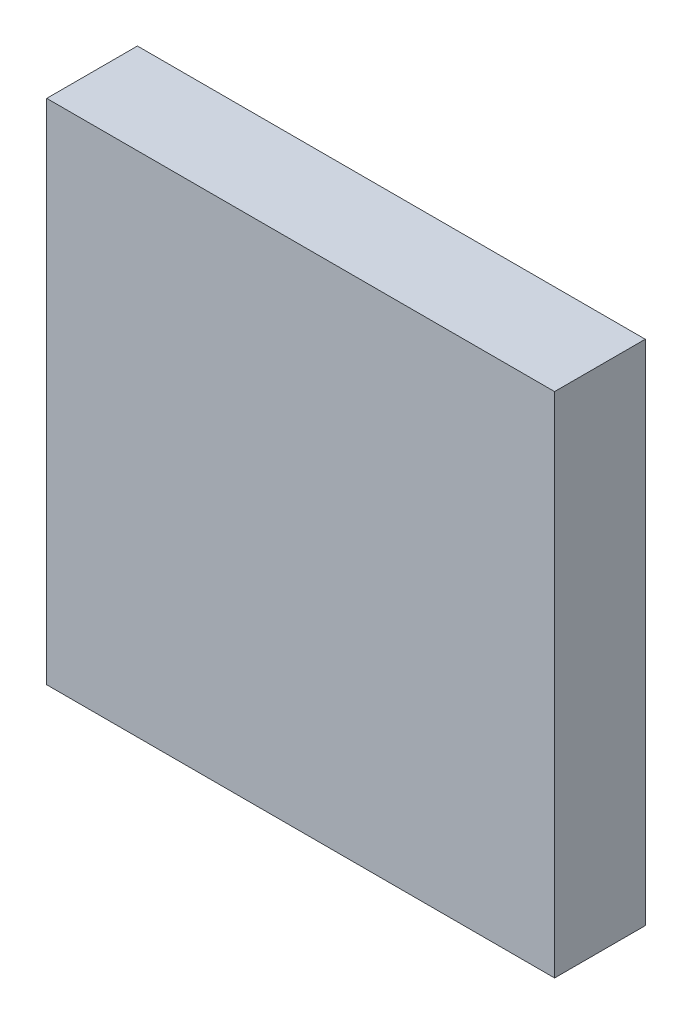
from build123d import *

# Parameters (mm, degrees)
SKETCH1_W           = 7
SKETCH1_H           = 7
BOSS_EXTRUDE1_DEPTH = 1.25


with BuildPart() as part:
    # Sketch1 → Boss-Extrude1 (new body)
    with BuildSketch(Plane.XY):
        Rectangle(SKETCH1_W, SKETCH1_H)
    extrude(amount=BOSS_EXTRUDE1_DEPTH)


solid = part.part
